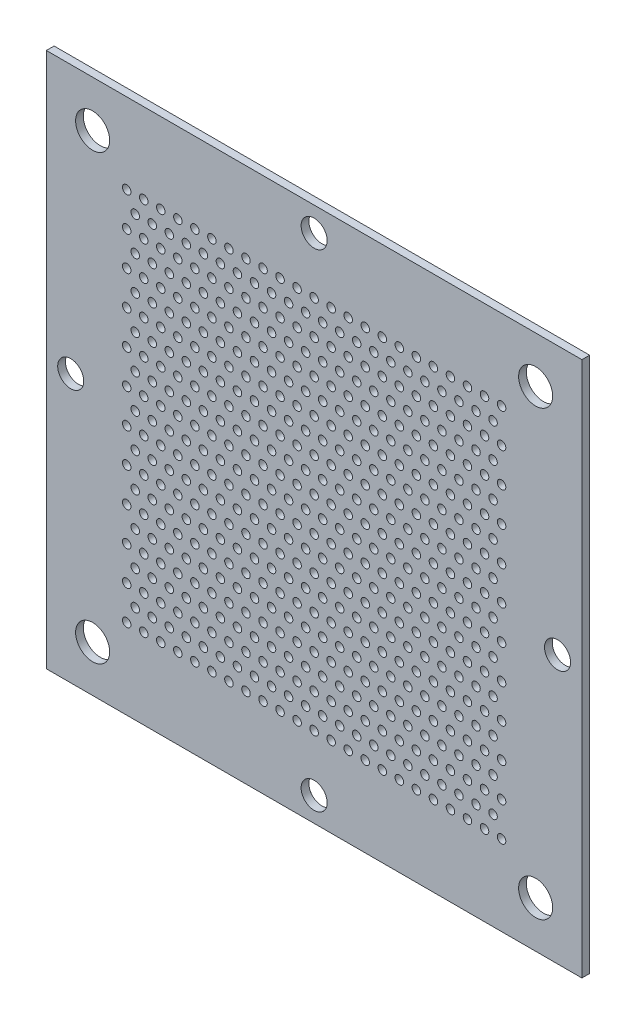
from build123d import *

# Parameters (mm, degrees)
MODEL_W             = 110
MODEL_H             = 110
MODEL_R             = 3.5
MODEL_R_2           = 0.875
MODEL_R_3           = 2.675
BOSS_EXTRUDE1_DEPTH = 1.5875


with BuildPart() as part:
    # Model → Boss-Extrude1 (new body)
    with BuildSketch(Plane.XY):
        with Locations((38.5, 38.5)):
            Rectangle(MODEL_W, MODEL_H)
        with Locations((84, 84)):
            Circle(MODEL_R, mode=Mode.SUBTRACT)
        with Locations((-7, 84)):
            Circle(MODEL_R, mode=Mode.SUBTRACT)
        with Locations((-7, -7)):
            Circle(MODEL_R, mode=Mode.SUBTRACT)
        with Locations((84, -7)):
            Circle(MODEL_R, mode=Mode.SUBTRACT)
        with Locations((77, 0)):
            Circle(MODEL_R_2, mode=Mode.SUBTRACT)
        with Locations((73.5, 0)):
            Circle(MODEL_R_2, mode=Mode.SUBTRACT)
        with Locations((70, 0)):
            Circle(MODEL_R_2, mode=Mode.SUBTRACT)
        with Locations((66.5, 0)):
            Circle(MODEL_R_2, mode=Mode.SUBTRACT)
        with Locations((63, 0)):
            Circle(MODEL_R_2, mode=Mode.SUBTRACT)
        with Locations((59.5, 0)):
            Circle(MODEL_R_2, mode=Mode.SUBTRACT)
        with Locations((56, 0)):
            Circle(MODEL_R_2, mode=Mode.SUBTRACT)
        with Locations((52.5, 0)):
            Circle(MODEL_R_2, mode=Mode.SUBTRACT)
        with Locations((49, 0)):
            Circle(MODEL_R_2, mode=Mode.SUBTRACT)
        with Locations((45.5, 0)):
            Circle(MODEL_R_2, mode=Mode.SUBTRACT)
        with Locations((42, 0)):
            Circle(MODEL_R_2, mode=Mode.SUBTRACT)
        with Locations((38.5, 0)):
            Circle(MODEL_R_2, mode=Mode.SUBTRACT)
        with Locations((35, 0)):
            Circle(MODEL_R_2, mode=Mode.SUBTRACT)
        with Locations((31.5, 0)):
            Circle(MODEL_R_2, mode=Mode.SUBTRACT)
        with Locations((28, 0)):
            Circle(MODEL_R_2, mode=Mode.SUBTRACT)
        with Locations((24.5, 0)):
            Circle(MODEL_R_2, mode=Mode.SUBTRACT)
        with Locations((21, 0)):
            Circle(MODEL_R_2, mode=Mode.SUBTRACT)
        with Locations((17.5, 0)):
            Circle(MODEL_R_2, mode=Mode.SUBTRACT)
        with Locations((14, 0)):
            Circle(MODEL_R_2, mode=Mode.SUBTRACT)
        with Locations((10.5, 0)):
            Circle(MODEL_R_2, mode=Mode.SUBTRACT)
        with Locations((7, 0)):
            Circle(MODEL_R_2, mode=Mode.SUBTRACT)
        with Locations((3.5, 0)):
            Circle(MODEL_R_2, mode=Mode.SUBTRACT)
        Circle(MODEL_R_2, mode=Mode.SUBTRACT)
        with Locations((75.25, 3.5)):
            Circle(MODEL_R_2, mode=Mode.SUBTRACT)
        with Locations((71.75, 3.5)):
            Circle(MODEL_R_2, mode=Mode.SUBTRACT)
        with Locations((68.25, 3.5)):
            Circle(MODEL_R_2, mode=Mode.SUBTRACT)
        with Locations((64.75, 3.5)):
            Circle(MODEL_R_2, mode=Mode.SUBTRACT)
        with Locations((61.25, 3.5)):
            Circle(MODEL_R_2, mode=Mode.SUBTRACT)
        with Locations((57.75, 3.5)):
            Circle(MODEL_R_2, mode=Mode.SUBTRACT)
        with Locations((54.25, 3.5)):
            Circle(MODEL_R_2, mode=Mode.SUBTRACT)
        with Locations((50.75, 3.5)):
            Circle(MODEL_R_2, mode=Mode.SUBTRACT)
        with Locations((47.25, 3.5)):
            Circle(MODEL_R_2, mode=Mode.SUBTRACT)
        with Locations((43.75, 3.5)):
            Circle(MODEL_R_2, mode=Mode.SUBTRACT)
        with Locations((40.25, 3.5)):
            Circle(MODEL_R_2, mode=Mode.SUBTRACT)
        with Locations((36.75, 3.5)):
            Circle(MODEL_R_2, mode=Mode.SUBTRACT)
        with Locations((33.25, 3.5)):
            Circle(MODEL_R_2, mode=Mode.SUBTRACT)
        with Locations((29.75, 3.5)):
            Circle(MODEL_R_2, mode=Mode.SUBTRACT)
        with Locations((26.25, 3.5)):
            Circle(MODEL_R_2, mode=Mode.SUBTRACT)
        with Locations((22.75, 3.5)):
            Circle(MODEL_R_2, mode=Mode.SUBTRACT)
        with Locations((19.25, 3.5)):
            Circle(MODEL_R_2, mode=Mode.SUBTRACT)
        with Locations((15.75, 3.5)):
            Circle(MODEL_R_2, mode=Mode.SUBTRACT)
        with Locations((12.25, 3.5)):
            Circle(MODEL_R_2, mode=Mode.SUBTRACT)
        with Locations((8.75, 3.5)):
            Circle(MODEL_R_2, mode=Mode.SUBTRACT)
        with Locations((5.25, 3.5)):
            Circle(MODEL_R_2, mode=Mode.SUBTRACT)
        with Locations((1.75, 3.5)):
            Circle(MODEL_R_2, mode=Mode.SUBTRACT)
        with Locations((77, 7)):
            Circle(MODEL_R_2, mode=Mode.SUBTRACT)
        with Locations((73.5, 7)):
            Circle(MODEL_R_2, mode=Mode.SUBTRACT)
        with Locations((70, 7)):
            Circle(MODEL_R_2, mode=Mode.SUBTRACT)
        with Locations((66.5, 7)):
            Circle(MODEL_R_2, mode=Mode.SUBTRACT)
        with Locations((63, 7)):
            Circle(MODEL_R_2, mode=Mode.SUBTRACT)
        with Locations((59.5, 7)):
            Circle(MODEL_R_2, mode=Mode.SUBTRACT)
        with Locations((56, 7)):
            Circle(MODEL_R_2, mode=Mode.SUBTRACT)
        with Locations((52.5, 7)):
            Circle(MODEL_R_2, mode=Mode.SUBTRACT)
        with Locations((49, 7)):
            Circle(MODEL_R_2, mode=Mode.SUBTRACT)
        with Locations((45.5, 7)):
            Circle(MODEL_R_2, mode=Mode.SUBTRACT)
        with Locations((42, 7)):
            Circle(MODEL_R_2, mode=Mode.SUBTRACT)
        with Locations((38.5, 7)):
            Circle(MODEL_R_2, mode=Mode.SUBTRACT)
        with Locations((35, 7)):
            Circle(MODEL_R_2, mode=Mode.SUBTRACT)
        with Locations((31.5, 7)):
            Circle(MODEL_R_2, mode=Mode.SUBTRACT)
        with Locations((28, 7)):
            Circle(MODEL_R_2, mode=Mode.SUBTRACT)
        with Locations((24.5, 7)):
            Circle(MODEL_R_2, mode=Mode.SUBTRACT)
        with Locations((21, 7)):
            Circle(MODEL_R_2, mode=Mode.SUBTRACT)
        with Locations((17.5, 7)):
            Circle(MODEL_R_2, mode=Mode.SUBTRACT)
        with Locations((14, 7)):
            Circle(MODEL_R_2, mode=Mode.SUBTRACT)
        with Locations((10.5, 7)):
            Circle(MODEL_R_2, mode=Mode.SUBTRACT)
        with Locations((7, 7)):
            Circle(MODEL_R_2, mode=Mode.SUBTRACT)
        with Locations((3.5, 7)):
            Circle(MODEL_R_2, mode=Mode.SUBTRACT)
        with Locations((0, 7)):
            Circle(MODEL_R_2, mode=Mode.SUBTRACT)
        with Locations((75.25, 10.5)):
            Circle(MODEL_R_2, mode=Mode.SUBTRACT)
        with Locations((71.75, 10.5)):
            Circle(MODEL_R_2, mode=Mode.SUBTRACT)
        with Locations((68.25, 10.5)):
            Circle(MODEL_R_2, mode=Mode.SUBTRACT)
        with Locations((64.75, 10.5)):
            Circle(MODEL_R_2, mode=Mode.SUBTRACT)
        with Locations((61.25, 10.5)):
            Circle(MODEL_R_2, mode=Mode.SUBTRACT)
        with Locations((57.75, 10.5)):
            Circle(MODEL_R_2, mode=Mode.SUBTRACT)
        with Locations((54.25, 10.5)):
            Circle(MODEL_R_2, mode=Mode.SUBTRACT)
        with Locations((50.75, 10.5)):
            Circle(MODEL_R_2, mode=Mode.SUBTRACT)
        with Locations((47.25, 10.5)):
            Circle(MODEL_R_2, mode=Mode.SUBTRACT)
        with Locations((43.75, 10.5)):
            Circle(MODEL_R_2, mode=Mode.SUBTRACT)
        with Locations((40.25, 10.5)):
            Circle(MODEL_R_2, mode=Mode.SUBTRACT)
        with Locations((36.75, 10.5)):
            Circle(MODEL_R_2, mode=Mode.SUBTRACT)
        with Locations((33.25, 10.5)):
            Circle(MODEL_R_2, mode=Mode.SUBTRACT)
        with Locations((29.75, 10.5)):
            Circle(MODEL_R_2, mode=Mode.SUBTRACT)
        with Locations((26.25, 10.5)):
            Circle(MODEL_R_2, mode=Mode.SUBTRACT)
        with Locations((22.75, 10.5)):
            Circle(MODEL_R_2, mode=Mode.SUBTRACT)
        with Locations((19.25, 10.5)):
            Circle(MODEL_R_2, mode=Mode.SUBTRACT)
        with Locations((15.75, 10.5)):
            Circle(MODEL_R_2, mode=Mode.SUBTRACT)
        with Locations((12.25, 10.5)):
            Circle(MODEL_R_2, mode=Mode.SUBTRACT)
        with Locations((8.75, 10.5)):
            Circle(MODEL_R_2, mode=Mode.SUBTRACT)
        with Locations((5.25, 10.5)):
            Circle(MODEL_R_2, mode=Mode.SUBTRACT)
        with Locations((1.75, 10.5)):
            Circle(MODEL_R_2, mode=Mode.SUBTRACT)
        with Locations((77, 14)):
            Circle(MODEL_R_2, mode=Mode.SUBTRACT)
        with Locations((73.5, 14)):
            Circle(MODEL_R_2, mode=Mode.SUBTRACT)
        with Locations((70, 14)):
            Circle(MODEL_R_2, mode=Mode.SUBTRACT)
        with Locations((66.5, 14)):
            Circle(MODEL_R_2, mode=Mode.SUBTRACT)
        with Locations((63, 14)):
            Circle(MODEL_R_2, mode=Mode.SUBTRACT)
        with Locations((59.5, 14)):
            Circle(MODEL_R_2, mode=Mode.SUBTRACT)
        with Locations((56, 14)):
            Circle(MODEL_R_2, mode=Mode.SUBTRACT)
        with Locations((52.5, 14)):
            Circle(MODEL_R_2, mode=Mode.SUBTRACT)
        with Locations((49, 14)):
            Circle(MODEL_R_2, mode=Mode.SUBTRACT)
        with Locations((45.5, 14)):
            Circle(MODEL_R_2, mode=Mode.SUBTRACT)
        with Locations((42, 14)):
            Circle(MODEL_R_2, mode=Mode.SUBTRACT)
        with Locations((38.5, 14)):
            Circle(MODEL_R_2, mode=Mode.SUBTRACT)
        with Locations((35, 14)):
            Circle(MODEL_R_2, mode=Mode.SUBTRACT)
        with Locations((31.5, 14)):
            Circle(MODEL_R_2, mode=Mode.SUBTRACT)
        with Locations((28, 14)):
            Circle(MODEL_R_2, mode=Mode.SUBTRACT)
        with Locations((24.5, 14)):
            Circle(MODEL_R_2, mode=Mode.SUBTRACT)
        with Locations((21, 14)):
            Circle(MODEL_R_2, mode=Mode.SUBTRACT)
        with Locations((17.5, 14)):
            Circle(MODEL_R_2, mode=Mode.SUBTRACT)
        with Locations((14, 14)):
            Circle(MODEL_R_2, mode=Mode.SUBTRACT)
        with Locations((10.5, 14)):
            Circle(MODEL_R_2, mode=Mode.SUBTRACT)
        with Locations((7, 14)):
            Circle(MODEL_R_2, mode=Mode.SUBTRACT)
        with Locations((3.5, 14)):
            Circle(MODEL_R_2, mode=Mode.SUBTRACT)
        with Locations((0, 14)):
            Circle(MODEL_R_2, mode=Mode.SUBTRACT)
        with Locations((75.25, 17.5)):
            Circle(MODEL_R_2, mode=Mode.SUBTRACT)
        with Locations((71.75, 17.5)):
            Circle(MODEL_R_2, mode=Mode.SUBTRACT)
        with Locations((68.25, 17.5)):
            Circle(MODEL_R_2, mode=Mode.SUBTRACT)
        with Locations((64.75, 17.5)):
            Circle(MODEL_R_2, mode=Mode.SUBTRACT)
        with Locations((61.25, 17.5)):
            Circle(MODEL_R_2, mode=Mode.SUBTRACT)
        with Locations((57.75, 17.5)):
            Circle(MODEL_R_2, mode=Mode.SUBTRACT)
        with Locations((54.25, 17.5)):
            Circle(MODEL_R_2, mode=Mode.SUBTRACT)
        with Locations((50.75, 17.5)):
            Circle(MODEL_R_2, mode=Mode.SUBTRACT)
        with Locations((47.25, 17.5)):
            Circle(MODEL_R_2, mode=Mode.SUBTRACT)
        with Locations((43.75, 17.5)):
            Circle(MODEL_R_2, mode=Mode.SUBTRACT)
        with Locations((40.25, 17.5)):
            Circle(MODEL_R_2, mode=Mode.SUBTRACT)
        with Locations((36.75, 17.5)):
            Circle(MODEL_R_2, mode=Mode.SUBTRACT)
        with Locations((33.25, 17.5)):
            Circle(MODEL_R_2, mode=Mode.SUBTRACT)
        with Locations((29.75, 17.5)):
            Circle(MODEL_R_2, mode=Mode.SUBTRACT)
        with Locations((26.25, 17.5)):
            Circle(MODEL_R_2, mode=Mode.SUBTRACT)
        with Locations((22.75, 17.5)):
            Circle(MODEL_R_2, mode=Mode.SUBTRACT)
        with Locations((19.25, 17.5)):
            Circle(MODEL_R_2, mode=Mode.SUBTRACT)
        with Locations((15.75, 17.5)):
            Circle(MODEL_R_2, mode=Mode.SUBTRACT)
        with Locations((12.25, 17.5)):
            Circle(MODEL_R_2, mode=Mode.SUBTRACT)
        with Locations((8.75, 17.5)):
            Circle(MODEL_R_2, mode=Mode.SUBTRACT)
        with Locations((5.25, 17.5)):
            Circle(MODEL_R_2, mode=Mode.SUBTRACT)
        with Locations((1.75, 17.5)):
            Circle(MODEL_R_2, mode=Mode.SUBTRACT)
        with Locations((77, 21)):
            Circle(MODEL_R_2, mode=Mode.SUBTRACT)
        with Locations((73.5, 21)):
            Circle(MODEL_R_2, mode=Mode.SUBTRACT)
        with Locations((70, 21)):
            Circle(MODEL_R_2, mode=Mode.SUBTRACT)
        with Locations((66.5, 21)):
            Circle(MODEL_R_2, mode=Mode.SUBTRACT)
        with Locations((63, 21)):
            Circle(MODEL_R_2, mode=Mode.SUBTRACT)
        with Locations((59.5, 21)):
            Circle(MODEL_R_2, mode=Mode.SUBTRACT)
        with Locations((56, 21)):
            Circle(MODEL_R_2, mode=Mode.SUBTRACT)
        with Locations((52.5, 21)):
            Circle(MODEL_R_2, mode=Mode.SUBTRACT)
        with Locations((49, 21)):
            Circle(MODEL_R_2, mode=Mode.SUBTRACT)
        with Locations((45.5, 21)):
            Circle(MODEL_R_2, mode=Mode.SUBTRACT)
        with Locations((42, 21)):
            Circle(MODEL_R_2, mode=Mode.SUBTRACT)
        with Locations((38.5, 21)):
            Circle(MODEL_R_2, mode=Mode.SUBTRACT)
        with Locations((35, 21)):
            Circle(MODEL_R_2, mode=Mode.SUBTRACT)
        with Locations((31.5, 21)):
            Circle(MODEL_R_2, mode=Mode.SUBTRACT)
        with Locations((28, 21)):
            Circle(MODEL_R_2, mode=Mode.SUBTRACT)
        with Locations((24.5, 21)):
            Circle(MODEL_R_2, mode=Mode.SUBTRACT)
        with Locations((21, 21)):
            Circle(MODEL_R_2, mode=Mode.SUBTRACT)
        with Locations((17.5, 21)):
            Circle(MODEL_R_2, mode=Mode.SUBTRACT)
        with Locations((14, 21)):
            Circle(MODEL_R_2, mode=Mode.SUBTRACT)
        with Locations((10.5, 21)):
            Circle(MODEL_R_2, mode=Mode.SUBTRACT)
        with Locations((7, 21)):
            Circle(MODEL_R_2, mode=Mode.SUBTRACT)
        with Locations((3.5, 21)):
            Circle(MODEL_R_2, mode=Mode.SUBTRACT)
        with Locations((0, 21)):
            Circle(MODEL_R_2, mode=Mode.SUBTRACT)
        with Locations((75.25, 24.5)):
            Circle(MODEL_R_2, mode=Mode.SUBTRACT)
        with Locations((71.75, 24.5)):
            Circle(MODEL_R_2, mode=Mode.SUBTRACT)
        with Locations((68.25, 24.5)):
            Circle(MODEL_R_2, mode=Mode.SUBTRACT)
        with Locations((64.75, 24.5)):
            Circle(MODEL_R_2, mode=Mode.SUBTRACT)
        with Locations((61.25, 24.5)):
            Circle(MODEL_R_2, mode=Mode.SUBTRACT)
        with Locations((57.75, 24.5)):
            Circle(MODEL_R_2, mode=Mode.SUBTRACT)
        with Locations((54.25, 24.5)):
            Circle(MODEL_R_2, mode=Mode.SUBTRACT)
        with Locations((50.75, 24.5)):
            Circle(MODEL_R_2, mode=Mode.SUBTRACT)
        with Locations((47.25, 24.5)):
            Circle(MODEL_R_2, mode=Mode.SUBTRACT)
        with Locations((43.75, 24.5)):
            Circle(MODEL_R_2, mode=Mode.SUBTRACT)
        with Locations((40.25, 24.5)):
            Circle(MODEL_R_2, mode=Mode.SUBTRACT)
        with Locations((36.75, 24.5)):
            Circle(MODEL_R_2, mode=Mode.SUBTRACT)
        with Locations((33.25, 24.5)):
            Circle(MODEL_R_2, mode=Mode.SUBTRACT)
        with Locations((29.75, 24.5)):
            Circle(MODEL_R_2, mode=Mode.SUBTRACT)
        with Locations((26.25, 24.5)):
            Circle(MODEL_R_2, mode=Mode.SUBTRACT)
        with Locations((22.75, 24.5)):
            Circle(MODEL_R_2, mode=Mode.SUBTRACT)
        with Locations((19.25, 24.5)):
            Circle(MODEL_R_2, mode=Mode.SUBTRACT)
        with Locations((15.75, 24.5)):
            Circle(MODEL_R_2, mode=Mode.SUBTRACT)
        with Locations((12.25, 24.5)):
            Circle(MODEL_R_2, mode=Mode.SUBTRACT)
        with Locations((8.75, 24.5)):
            Circle(MODEL_R_2, mode=Mode.SUBTRACT)
        with Locations((5.25, 24.5)):
            Circle(MODEL_R_2, mode=Mode.SUBTRACT)
        with Locations((1.75, 24.5)):
            Circle(MODEL_R_2, mode=Mode.SUBTRACT)
        with Locations((77, 28)):
            Circle(MODEL_R_2, mode=Mode.SUBTRACT)
        with Locations((73.5, 28)):
            Circle(MODEL_R_2, mode=Mode.SUBTRACT)
        with Locations((70, 28)):
            Circle(MODEL_R_2, mode=Mode.SUBTRACT)
        with Locations((66.5, 28)):
            Circle(MODEL_R_2, mode=Mode.SUBTRACT)
        with Locations((63, 28)):
            Circle(MODEL_R_2, mode=Mode.SUBTRACT)
        with Locations((59.5, 28)):
            Circle(MODEL_R_2, mode=Mode.SUBTRACT)
        with Locations((56, 28)):
            Circle(MODEL_R_2, mode=Mode.SUBTRACT)
        with Locations((52.5, 28)):
            Circle(MODEL_R_2, mode=Mode.SUBTRACT)
        with Locations((49, 28)):
            Circle(MODEL_R_2, mode=Mode.SUBTRACT)
        with Locations((45.5, 28)):
            Circle(MODEL_R_2, mode=Mode.SUBTRACT)
        with Locations((42, 28)):
            Circle(MODEL_R_2, mode=Mode.SUBTRACT)
        with Locations((38.5, 28)):
            Circle(MODEL_R_2, mode=Mode.SUBTRACT)
        with Locations((35, 28)):
            Circle(MODEL_R_2, mode=Mode.SUBTRACT)
        with Locations((31.5, 28)):
            Circle(MODEL_R_2, mode=Mode.SUBTRACT)
        with Locations((28, 28)):
            Circle(MODEL_R_2, mode=Mode.SUBTRACT)
        with Locations((24.5, 28)):
            Circle(MODEL_R_2, mode=Mode.SUBTRACT)
        with Locations((21, 28)):
            Circle(MODEL_R_2, mode=Mode.SUBTRACT)
        with Locations((17.5, 28)):
            Circle(MODEL_R_2, mode=Mode.SUBTRACT)
        with Locations((14, 28)):
            Circle(MODEL_R_2, mode=Mode.SUBTRACT)
        with Locations((10.5, 28)):
            Circle(MODEL_R_2, mode=Mode.SUBTRACT)
        with Locations((7, 28)):
            Circle(MODEL_R_2, mode=Mode.SUBTRACT)
        with Locations((3.5, 28)):
            Circle(MODEL_R_2, mode=Mode.SUBTRACT)
        with Locations((0, 28)):
            Circle(MODEL_R_2, mode=Mode.SUBTRACT)
        with Locations((75.25, 31.5)):
            Circle(MODEL_R_2, mode=Mode.SUBTRACT)
        with Locations((71.75, 31.5)):
            Circle(MODEL_R_2, mode=Mode.SUBTRACT)
        with Locations((68.25, 31.5)):
            Circle(MODEL_R_2, mode=Mode.SUBTRACT)
        with Locations((64.75, 31.5)):
            Circle(MODEL_R_2, mode=Mode.SUBTRACT)
        with Locations((61.25, 31.5)):
            Circle(MODEL_R_2, mode=Mode.SUBTRACT)
        with Locations((57.75, 31.5)):
            Circle(MODEL_R_2, mode=Mode.SUBTRACT)
        with Locations((54.25, 31.5)):
            Circle(MODEL_R_2, mode=Mode.SUBTRACT)
        with Locations((50.75, 31.5)):
            Circle(MODEL_R_2, mode=Mode.SUBTRACT)
        with Locations((47.25, 31.5)):
            Circle(MODEL_R_2, mode=Mode.SUBTRACT)
        with Locations((43.75, 31.5)):
            Circle(MODEL_R_2, mode=Mode.SUBTRACT)
        with Locations((40.25, 31.5)):
            Circle(MODEL_R_2, mode=Mode.SUBTRACT)
        with Locations((36.75, 31.5)):
            Circle(MODEL_R_2, mode=Mode.SUBTRACT)
        with Locations((33.25, 31.5)):
            Circle(MODEL_R_2, mode=Mode.SUBTRACT)
        with Locations((29.75, 31.5)):
            Circle(MODEL_R_2, mode=Mode.SUBTRACT)
        with Locations((26.25, 31.5)):
            Circle(MODEL_R_2, mode=Mode.SUBTRACT)
        with Locations((22.75, 31.5)):
            Circle(MODEL_R_2, mode=Mode.SUBTRACT)
        with Locations((19.25, 31.5)):
            Circle(MODEL_R_2, mode=Mode.SUBTRACT)
        with Locations((15.75, 31.5)):
            Circle(MODEL_R_2, mode=Mode.SUBTRACT)
        with Locations((12.25, 31.5)):
            Circle(MODEL_R_2, mode=Mode.SUBTRACT)
        with Locations((8.75, 31.5)):
            Circle(MODEL_R_2, mode=Mode.SUBTRACT)
        with Locations((5.25, 31.5)):
            Circle(MODEL_R_2, mode=Mode.SUBTRACT)
        with Locations((1.75, 31.5)):
            Circle(MODEL_R_2, mode=Mode.SUBTRACT)
        with Locations((77, 35)):
            Circle(MODEL_R_2, mode=Mode.SUBTRACT)
        with Locations((73.5, 35)):
            Circle(MODEL_R_2, mode=Mode.SUBTRACT)
        with Locations((70, 35)):
            Circle(MODEL_R_2, mode=Mode.SUBTRACT)
        with Locations((66.5, 35)):
            Circle(MODEL_R_2, mode=Mode.SUBTRACT)
        with Locations((63, 35)):
            Circle(MODEL_R_2, mode=Mode.SUBTRACT)
        with Locations((59.5, 35)):
            Circle(MODEL_R_2, mode=Mode.SUBTRACT)
        with Locations((56, 35)):
            Circle(MODEL_R_2, mode=Mode.SUBTRACT)
        with Locations((52.5, 35)):
            Circle(MODEL_R_2, mode=Mode.SUBTRACT)
        with Locations((49, 35)):
            Circle(MODEL_R_2, mode=Mode.SUBTRACT)
        with Locations((45.5, 35)):
            Circle(MODEL_R_2, mode=Mode.SUBTRACT)
        with Locations((42, 35)):
            Circle(MODEL_R_2, mode=Mode.SUBTRACT)
        with Locations((38.5, 35)):
            Circle(MODEL_R_2, mode=Mode.SUBTRACT)
        with Locations((35, 35)):
            Circle(MODEL_R_2, mode=Mode.SUBTRACT)
        with Locations((31.5, 35)):
            Circle(MODEL_R_2, mode=Mode.SUBTRACT)
        with Locations((28, 35)):
            Circle(MODEL_R_2, mode=Mode.SUBTRACT)
        with Locations((24.5, 35)):
            Circle(MODEL_R_2, mode=Mode.SUBTRACT)
        with Locations((21, 35)):
            Circle(MODEL_R_2, mode=Mode.SUBTRACT)
        with Locations((17.5, 35)):
            Circle(MODEL_R_2, mode=Mode.SUBTRACT)
        with Locations((14, 35)):
            Circle(MODEL_R_2, mode=Mode.SUBTRACT)
        with Locations((10.5, 35)):
            Circle(MODEL_R_2, mode=Mode.SUBTRACT)
        with Locations((7, 35)):
            Circle(MODEL_R_2, mode=Mode.SUBTRACT)
        with Locations((3.5, 35)):
            Circle(MODEL_R_2, mode=Mode.SUBTRACT)
        with Locations((0, 35)):
            Circle(MODEL_R_2, mode=Mode.SUBTRACT)
        with Locations((75.25, 38.5)):
            Circle(MODEL_R_2, mode=Mode.SUBTRACT)
        with Locations((71.75, 38.5)):
            Circle(MODEL_R_2, mode=Mode.SUBTRACT)
        with Locations((68.25, 38.5)):
            Circle(MODEL_R_2, mode=Mode.SUBTRACT)
        with Locations((64.75, 38.5)):
            Circle(MODEL_R_2, mode=Mode.SUBTRACT)
        with Locations((61.25, 38.5)):
            Circle(MODEL_R_2, mode=Mode.SUBTRACT)
        with Locations((57.75, 38.5)):
            Circle(MODEL_R_2, mode=Mode.SUBTRACT)
        with Locations((54.25, 38.5)):
            Circle(MODEL_R_2, mode=Mode.SUBTRACT)
        with Locations((50.75, 38.5)):
            Circle(MODEL_R_2, mode=Mode.SUBTRACT)
        with Locations((47.25, 38.5)):
            Circle(MODEL_R_2, mode=Mode.SUBTRACT)
        with Locations((43.75, 38.5)):
            Circle(MODEL_R_2, mode=Mode.SUBTRACT)
        with Locations((40.25, 38.5)):
            Circle(MODEL_R_2, mode=Mode.SUBTRACT)
        with Locations((36.75, 38.5)):
            Circle(MODEL_R_2, mode=Mode.SUBTRACT)
        with Locations((33.25, 38.5)):
            Circle(MODEL_R_2, mode=Mode.SUBTRACT)
        with Locations((29.75, 38.5)):
            Circle(MODEL_R_2, mode=Mode.SUBTRACT)
        with Locations((26.25, 38.5)):
            Circle(MODEL_R_2, mode=Mode.SUBTRACT)
        with Locations((22.75, 38.5)):
            Circle(MODEL_R_2, mode=Mode.SUBTRACT)
        with Locations((19.25, 38.5)):
            Circle(MODEL_R_2, mode=Mode.SUBTRACT)
        with Locations((15.75, 38.5)):
            Circle(MODEL_R_2, mode=Mode.SUBTRACT)
        with Locations((12.25, 38.5)):
            Circle(MODEL_R_2, mode=Mode.SUBTRACT)
        with Locations((8.75, 38.5)):
            Circle(MODEL_R_2, mode=Mode.SUBTRACT)
        with Locations((5.25, 38.5)):
            Circle(MODEL_R_2, mode=Mode.SUBTRACT)
        with Locations((1.75, 38.5)):
            Circle(MODEL_R_2, mode=Mode.SUBTRACT)
        with Locations((77, 42)):
            Circle(MODEL_R_2, mode=Mode.SUBTRACT)
        with Locations((73.5, 42)):
            Circle(MODEL_R_2, mode=Mode.SUBTRACT)
        with Locations((70, 42)):
            Circle(MODEL_R_2, mode=Mode.SUBTRACT)
        with Locations((66.5, 42)):
            Circle(MODEL_R_2, mode=Mode.SUBTRACT)
        with Locations((63, 42)):
            Circle(MODEL_R_2, mode=Mode.SUBTRACT)
        with Locations((59.5, 42)):
            Circle(MODEL_R_2, mode=Mode.SUBTRACT)
        with Locations((56, 42)):
            Circle(MODEL_R_2, mode=Mode.SUBTRACT)
        with Locations((52.5, 42)):
            Circle(MODEL_R_2, mode=Mode.SUBTRACT)
        with Locations((49, 42)):
            Circle(MODEL_R_2, mode=Mode.SUBTRACT)
        with Locations((45.5, 42)):
            Circle(MODEL_R_2, mode=Mode.SUBTRACT)
        with Locations((42, 42)):
            Circle(MODEL_R_2, mode=Mode.SUBTRACT)
        with Locations((38.5, 42)):
            Circle(MODEL_R_2, mode=Mode.SUBTRACT)
        with Locations((35, 42)):
            Circle(MODEL_R_2, mode=Mode.SUBTRACT)
        with Locations((31.5, 42)):
            Circle(MODEL_R_2, mode=Mode.SUBTRACT)
        with Locations((28, 42)):
            Circle(MODEL_R_2, mode=Mode.SUBTRACT)
        with Locations((24.5, 42)):
            Circle(MODEL_R_2, mode=Mode.SUBTRACT)
        with Locations((21, 42)):
            Circle(MODEL_R_2, mode=Mode.SUBTRACT)
        with Locations((17.5, 42)):
            Circle(MODEL_R_2, mode=Mode.SUBTRACT)
        with Locations((14, 42)):
            Circle(MODEL_R_2, mode=Mode.SUBTRACT)
        with Locations((10.5, 42)):
            Circle(MODEL_R_2, mode=Mode.SUBTRACT)
        with Locations((7, 42)):
            Circle(MODEL_R_2, mode=Mode.SUBTRACT)
        with Locations((3.5, 42)):
            Circle(MODEL_R_2, mode=Mode.SUBTRACT)
        with Locations((0, 42)):
            Circle(MODEL_R_2, mode=Mode.SUBTRACT)
        with Locations((75.25, 45.5)):
            Circle(MODEL_R_2, mode=Mode.SUBTRACT)
        with Locations((71.75, 45.5)):
            Circle(MODEL_R_2, mode=Mode.SUBTRACT)
        with Locations((68.25, 45.5)):
            Circle(MODEL_R_2, mode=Mode.SUBTRACT)
        with Locations((64.75, 45.5)):
            Circle(MODEL_R_2, mode=Mode.SUBTRACT)
        with Locations((61.25, 45.5)):
            Circle(MODEL_R_2, mode=Mode.SUBTRACT)
        with Locations((57.75, 45.5)):
            Circle(MODEL_R_2, mode=Mode.SUBTRACT)
        with Locations((54.25, 45.5)):
            Circle(MODEL_R_2, mode=Mode.SUBTRACT)
        with Locations((50.75, 45.5)):
            Circle(MODEL_R_2, mode=Mode.SUBTRACT)
        with Locations((47.25, 45.5)):
            Circle(MODEL_R_2, mode=Mode.SUBTRACT)
        with Locations((43.75, 45.5)):
            Circle(MODEL_R_2, mode=Mode.SUBTRACT)
        with Locations((40.25, 45.5)):
            Circle(MODEL_R_2, mode=Mode.SUBTRACT)
        with Locations((36.75, 45.5)):
            Circle(MODEL_R_2, mode=Mode.SUBTRACT)
        with Locations((33.25, 45.5)):
            Circle(MODEL_R_2, mode=Mode.SUBTRACT)
        with Locations((29.75, 45.5)):
            Circle(MODEL_R_2, mode=Mode.SUBTRACT)
        with Locations((26.25, 45.5)):
            Circle(MODEL_R_2, mode=Mode.SUBTRACT)
        with Locations((22.75, 45.5)):
            Circle(MODEL_R_2, mode=Mode.SUBTRACT)
        with Locations((19.25, 45.5)):
            Circle(MODEL_R_2, mode=Mode.SUBTRACT)
        with Locations((15.75, 45.5)):
            Circle(MODEL_R_2, mode=Mode.SUBTRACT)
        with Locations((12.25, 45.5)):
            Circle(MODEL_R_2, mode=Mode.SUBTRACT)
        with Locations((8.75, 45.5)):
            Circle(MODEL_R_2, mode=Mode.SUBTRACT)
        with Locations((5.25, 45.5)):
            Circle(MODEL_R_2, mode=Mode.SUBTRACT)
        with Locations((1.75, 45.5)):
            Circle(MODEL_R_2, mode=Mode.SUBTRACT)
        with Locations((77, 49)):
            Circle(MODEL_R_2, mode=Mode.SUBTRACT)
        with Locations((73.5, 49)):
            Circle(MODEL_R_2, mode=Mode.SUBTRACT)
        with Locations((70, 49)):
            Circle(MODEL_R_2, mode=Mode.SUBTRACT)
        with Locations((66.5, 49)):
            Circle(MODEL_R_2, mode=Mode.SUBTRACT)
        with Locations((63, 49)):
            Circle(MODEL_R_2, mode=Mode.SUBTRACT)
        with Locations((59.5, 49)):
            Circle(MODEL_R_2, mode=Mode.SUBTRACT)
        with Locations((56, 49)):
            Circle(MODEL_R_2, mode=Mode.SUBTRACT)
        with Locations((52.5, 49)):
            Circle(MODEL_R_2, mode=Mode.SUBTRACT)
        with Locations((49, 49)):
            Circle(MODEL_R_2, mode=Mode.SUBTRACT)
        with Locations((45.5, 49)):
            Circle(MODEL_R_2, mode=Mode.SUBTRACT)
        with Locations((42, 49)):
            Circle(MODEL_R_2, mode=Mode.SUBTRACT)
        with Locations((38.5, 49)):
            Circle(MODEL_R_2, mode=Mode.SUBTRACT)
        with Locations((35, 49)):
            Circle(MODEL_R_2, mode=Mode.SUBTRACT)
        with Locations((31.5, 49)):
            Circle(MODEL_R_2, mode=Mode.SUBTRACT)
        with Locations((28, 49)):
            Circle(MODEL_R_2, mode=Mode.SUBTRACT)
        with Locations((24.5, 49)):
            Circle(MODEL_R_2, mode=Mode.SUBTRACT)
        with Locations((21, 49)):
            Circle(MODEL_R_2, mode=Mode.SUBTRACT)
        with Locations((17.5, 49)):
            Circle(MODEL_R_2, mode=Mode.SUBTRACT)
        with Locations((14, 49)):
            Circle(MODEL_R_2, mode=Mode.SUBTRACT)
        with Locations((10.5, 49)):
            Circle(MODEL_R_2, mode=Mode.SUBTRACT)
        with Locations((7, 49)):
            Circle(MODEL_R_2, mode=Mode.SUBTRACT)
        with Locations((3.5, 49)):
            Circle(MODEL_R_2, mode=Mode.SUBTRACT)
        with Locations((0, 49)):
            Circle(MODEL_R_2, mode=Mode.SUBTRACT)
        with Locations((75.25, 52.5)):
            Circle(MODEL_R_2, mode=Mode.SUBTRACT)
        with Locations((71.75, 52.5)):
            Circle(MODEL_R_2, mode=Mode.SUBTRACT)
        with Locations((68.25, 52.5)):
            Circle(MODEL_R_2, mode=Mode.SUBTRACT)
        with Locations((64.75, 52.5)):
            Circle(MODEL_R_2, mode=Mode.SUBTRACT)
        with Locations((61.25, 52.5)):
            Circle(MODEL_R_2, mode=Mode.SUBTRACT)
        with Locations((57.75, 52.5)):
            Circle(MODEL_R_2, mode=Mode.SUBTRACT)
        with Locations((54.25, 52.5)):
            Circle(MODEL_R_2, mode=Mode.SUBTRACT)
        with Locations((50.75, 52.5)):
            Circle(MODEL_R_2, mode=Mode.SUBTRACT)
        with Locations((47.25, 52.5)):
            Circle(MODEL_R_2, mode=Mode.SUBTRACT)
        with Locations((43.75, 52.5)):
            Circle(MODEL_R_2, mode=Mode.SUBTRACT)
        with Locations((40.25, 52.5)):
            Circle(MODEL_R_2, mode=Mode.SUBTRACT)
        with Locations((36.75, 52.5)):
            Circle(MODEL_R_2, mode=Mode.SUBTRACT)
        with Locations((33.25, 52.5)):
            Circle(MODEL_R_2, mode=Mode.SUBTRACT)
        with Locations((29.75, 52.5)):
            Circle(MODEL_R_2, mode=Mode.SUBTRACT)
        with Locations((26.25, 52.5)):
            Circle(MODEL_R_2, mode=Mode.SUBTRACT)
        with Locations((22.75, 52.5)):
            Circle(MODEL_R_2, mode=Mode.SUBTRACT)
        with Locations((19.25, 52.5)):
            Circle(MODEL_R_2, mode=Mode.SUBTRACT)
        with Locations((15.75, 52.5)):
            Circle(MODEL_R_2, mode=Mode.SUBTRACT)
        with Locations((12.25, 52.5)):
            Circle(MODEL_R_2, mode=Mode.SUBTRACT)
        with Locations((8.75, 52.5)):
            Circle(MODEL_R_2, mode=Mode.SUBTRACT)
        with Locations((5.25, 52.5)):
            Circle(MODEL_R_2, mode=Mode.SUBTRACT)
        with Locations((1.75, 52.5)):
            Circle(MODEL_R_2, mode=Mode.SUBTRACT)
        with Locations((77, 56)):
            Circle(MODEL_R_2, mode=Mode.SUBTRACT)
        with Locations((73.5, 56)):
            Circle(MODEL_R_2, mode=Mode.SUBTRACT)
        with Locations((70, 56)):
            Circle(MODEL_R_2, mode=Mode.SUBTRACT)
        with Locations((66.5, 56)):
            Circle(MODEL_R_2, mode=Mode.SUBTRACT)
        with Locations((63, 56)):
            Circle(MODEL_R_2, mode=Mode.SUBTRACT)
        with Locations((59.5, 56)):
            Circle(MODEL_R_2, mode=Mode.SUBTRACT)
        with Locations((56, 56)):
            Circle(MODEL_R_2, mode=Mode.SUBTRACT)
        with Locations((52.5, 56)):
            Circle(MODEL_R_2, mode=Mode.SUBTRACT)
        with Locations((49, 56)):
            Circle(MODEL_R_2, mode=Mode.SUBTRACT)
        with Locations((45.5, 56)):
            Circle(MODEL_R_2, mode=Mode.SUBTRACT)
        with Locations((42, 56)):
            Circle(MODEL_R_2, mode=Mode.SUBTRACT)
        with Locations((38.5, 56)):
            Circle(MODEL_R_2, mode=Mode.SUBTRACT)
        with Locations((35, 56)):
            Circle(MODEL_R_2, mode=Mode.SUBTRACT)
        with Locations((31.5, 56)):
            Circle(MODEL_R_2, mode=Mode.SUBTRACT)
        with Locations((28, 56)):
            Circle(MODEL_R_2, mode=Mode.SUBTRACT)
        with Locations((24.5, 56)):
            Circle(MODEL_R_2, mode=Mode.SUBTRACT)
        with Locations((21, 56)):
            Circle(MODEL_R_2, mode=Mode.SUBTRACT)
        with Locations((17.5, 56)):
            Circle(MODEL_R_2, mode=Mode.SUBTRACT)
        with Locations((14, 56)):
            Circle(MODEL_R_2, mode=Mode.SUBTRACT)
        with Locations((10.5, 56)):
            Circle(MODEL_R_2, mode=Mode.SUBTRACT)
        with Locations((7, 56)):
            Circle(MODEL_R_2, mode=Mode.SUBTRACT)
        with Locations((3.5, 56)):
            Circle(MODEL_R_2, mode=Mode.SUBTRACT)
        with Locations((0, 56)):
            Circle(MODEL_R_2, mode=Mode.SUBTRACT)
        with Locations((75.25, 59.5)):
            Circle(MODEL_R_2, mode=Mode.SUBTRACT)
        with Locations((71.75, 59.5)):
            Circle(MODEL_R_2, mode=Mode.SUBTRACT)
        with Locations((68.25, 59.5)):
            Circle(MODEL_R_2, mode=Mode.SUBTRACT)
        with Locations((64.75, 59.5)):
            Circle(MODEL_R_2, mode=Mode.SUBTRACT)
        with Locations((61.25, 59.5)):
            Circle(MODEL_R_2, mode=Mode.SUBTRACT)
        with Locations((57.75, 59.5)):
            Circle(MODEL_R_2, mode=Mode.SUBTRACT)
        with Locations((54.25, 59.5)):
            Circle(MODEL_R_2, mode=Mode.SUBTRACT)
        with Locations((50.75, 59.5)):
            Circle(MODEL_R_2, mode=Mode.SUBTRACT)
        with Locations((47.25, 59.5)):
            Circle(MODEL_R_2, mode=Mode.SUBTRACT)
        with Locations((43.75, 59.5)):
            Circle(MODEL_R_2, mode=Mode.SUBTRACT)
        with Locations((40.25, 59.5)):
            Circle(MODEL_R_2, mode=Mode.SUBTRACT)
        with Locations((36.75, 59.5)):
            Circle(MODEL_R_2, mode=Mode.SUBTRACT)
        with Locations((33.25, 59.5)):
            Circle(MODEL_R_2, mode=Mode.SUBTRACT)
        with Locations((29.75, 59.5)):
            Circle(MODEL_R_2, mode=Mode.SUBTRACT)
        with Locations((26.25, 59.5)):
            Circle(MODEL_R_2, mode=Mode.SUBTRACT)
        with Locations((22.75, 59.5)):
            Circle(MODEL_R_2, mode=Mode.SUBTRACT)
        with Locations((19.25, 59.5)):
            Circle(MODEL_R_2, mode=Mode.SUBTRACT)
        with Locations((15.75, 59.5)):
            Circle(MODEL_R_2, mode=Mode.SUBTRACT)
        with Locations((12.25, 59.5)):
            Circle(MODEL_R_2, mode=Mode.SUBTRACT)
        with Locations((8.75, 59.5)):
            Circle(MODEL_R_2, mode=Mode.SUBTRACT)
        with Locations((5.25, 59.5)):
            Circle(MODEL_R_2, mode=Mode.SUBTRACT)
        with Locations((1.75, 59.5)):
            Circle(MODEL_R_2, mode=Mode.SUBTRACT)
        with Locations((77, 63)):
            Circle(MODEL_R_2, mode=Mode.SUBTRACT)
        with Locations((73.5, 63)):
            Circle(MODEL_R_2, mode=Mode.SUBTRACT)
        with Locations((70, 63)):
            Circle(MODEL_R_2, mode=Mode.SUBTRACT)
        with Locations((66.5, 63)):
            Circle(MODEL_R_2, mode=Mode.SUBTRACT)
        with Locations((63, 63)):
            Circle(MODEL_R_2, mode=Mode.SUBTRACT)
        with Locations((59.5, 63)):
            Circle(MODEL_R_2, mode=Mode.SUBTRACT)
        with Locations((56, 63)):
            Circle(MODEL_R_2, mode=Mode.SUBTRACT)
        with Locations((52.5, 63)):
            Circle(MODEL_R_2, mode=Mode.SUBTRACT)
        with Locations((49, 63)):
            Circle(MODEL_R_2, mode=Mode.SUBTRACT)
        with Locations((45.5, 63)):
            Circle(MODEL_R_2, mode=Mode.SUBTRACT)
        with Locations((42, 63)):
            Circle(MODEL_R_2, mode=Mode.SUBTRACT)
        with Locations((38.5, 63)):
            Circle(MODEL_R_2, mode=Mode.SUBTRACT)
        with Locations((35, 63)):
            Circle(MODEL_R_2, mode=Mode.SUBTRACT)
        with Locations((31.5, 63)):
            Circle(MODEL_R_2, mode=Mode.SUBTRACT)
        with Locations((28, 63)):
            Circle(MODEL_R_2, mode=Mode.SUBTRACT)
        with Locations((24.5, 63)):
            Circle(MODEL_R_2, mode=Mode.SUBTRACT)
        with Locations((21, 63)):
            Circle(MODEL_R_2, mode=Mode.SUBTRACT)
        with Locations((17.5, 63)):
            Circle(MODEL_R_2, mode=Mode.SUBTRACT)
        with Locations((14, 63)):
            Circle(MODEL_R_2, mode=Mode.SUBTRACT)
        with Locations((10.5, 63)):
            Circle(MODEL_R_2, mode=Mode.SUBTRACT)
        with Locations((7, 63)):
            Circle(MODEL_R_2, mode=Mode.SUBTRACT)
        with Locations((3.5, 63)):
            Circle(MODEL_R_2, mode=Mode.SUBTRACT)
        with Locations((0, 63)):
            Circle(MODEL_R_2, mode=Mode.SUBTRACT)
        with Locations((75.25, 66.5)):
            Circle(MODEL_R_2, mode=Mode.SUBTRACT)
        with Locations((71.75, 66.5)):
            Circle(MODEL_R_2, mode=Mode.SUBTRACT)
        with Locations((68.25, 66.5)):
            Circle(MODEL_R_2, mode=Mode.SUBTRACT)
        with Locations((64.75, 66.5)):
            Circle(MODEL_R_2, mode=Mode.SUBTRACT)
        with Locations((61.25, 66.5)):
            Circle(MODEL_R_2, mode=Mode.SUBTRACT)
        with Locations((57.75, 66.5)):
            Circle(MODEL_R_2, mode=Mode.SUBTRACT)
        with Locations((54.25, 66.5)):
            Circle(MODEL_R_2, mode=Mode.SUBTRACT)
        with Locations((50.75, 66.5)):
            Circle(MODEL_R_2, mode=Mode.SUBTRACT)
        with Locations((47.25, 66.5)):
            Circle(MODEL_R_2, mode=Mode.SUBTRACT)
        with Locations((43.75, 66.5)):
            Circle(MODEL_R_2, mode=Mode.SUBTRACT)
        with Locations((40.25, 66.5)):
            Circle(MODEL_R_2, mode=Mode.SUBTRACT)
        with Locations((36.75, 66.5)):
            Circle(MODEL_R_2, mode=Mode.SUBTRACT)
        with Locations((33.25, 66.5)):
            Circle(MODEL_R_2, mode=Mode.SUBTRACT)
        with Locations((29.75, 66.5)):
            Circle(MODEL_R_2, mode=Mode.SUBTRACT)
        with Locations((26.25, 66.5)):
            Circle(MODEL_R_2, mode=Mode.SUBTRACT)
        with Locations((22.75, 66.5)):
            Circle(MODEL_R_2, mode=Mode.SUBTRACT)
        with Locations((19.25, 66.5)):
            Circle(MODEL_R_2, mode=Mode.SUBTRACT)
        with Locations((15.75, 66.5)):
            Circle(MODEL_R_2, mode=Mode.SUBTRACT)
        with Locations((12.25, 66.5)):
            Circle(MODEL_R_2, mode=Mode.SUBTRACT)
        with Locations((8.75, 66.5)):
            Circle(MODEL_R_2, mode=Mode.SUBTRACT)
        with Locations((5.25, 66.5)):
            Circle(MODEL_R_2, mode=Mode.SUBTRACT)
        with Locations((1.75, 66.5)):
            Circle(MODEL_R_2, mode=Mode.SUBTRACT)
        with Locations((77, 70)):
            Circle(MODEL_R_2, mode=Mode.SUBTRACT)
        with Locations((73.5, 70)):
            Circle(MODEL_R_2, mode=Mode.SUBTRACT)
        with Locations((70, 70)):
            Circle(MODEL_R_2, mode=Mode.SUBTRACT)
        with Locations((66.5, 70)):
            Circle(MODEL_R_2, mode=Mode.SUBTRACT)
        with Locations((63, 70)):
            Circle(MODEL_R_2, mode=Mode.SUBTRACT)
        with Locations((59.5, 70)):
            Circle(MODEL_R_2, mode=Mode.SUBTRACT)
        with Locations((56, 70)):
            Circle(MODEL_R_2, mode=Mode.SUBTRACT)
        with Locations((52.5, 70)):
            Circle(MODEL_R_2, mode=Mode.SUBTRACT)
        with Locations((49, 70)):
            Circle(MODEL_R_2, mode=Mode.SUBTRACT)
        with Locations((45.5, 70)):
            Circle(MODEL_R_2, mode=Mode.SUBTRACT)
        with Locations((42, 70)):
            Circle(MODEL_R_2, mode=Mode.SUBTRACT)
        with Locations((38.5, 70)):
            Circle(MODEL_R_2, mode=Mode.SUBTRACT)
        with Locations((35, 70)):
            Circle(MODEL_R_2, mode=Mode.SUBTRACT)
        with Locations((31.5, 70)):
            Circle(MODEL_R_2, mode=Mode.SUBTRACT)
        with Locations((28, 70)):
            Circle(MODEL_R_2, mode=Mode.SUBTRACT)
        with Locations((24.5, 70)):
            Circle(MODEL_R_2, mode=Mode.SUBTRACT)
        with Locations((21, 70)):
            Circle(MODEL_R_2, mode=Mode.SUBTRACT)
        with Locations((17.5, 70)):
            Circle(MODEL_R_2, mode=Mode.SUBTRACT)
        with Locations((14, 70)):
            Circle(MODEL_R_2, mode=Mode.SUBTRACT)
        with Locations((10.5, 70)):
            Circle(MODEL_R_2, mode=Mode.SUBTRACT)
        with Locations((7, 70)):
            Circle(MODEL_R_2, mode=Mode.SUBTRACT)
        with Locations((3.5, 70)):
            Circle(MODEL_R_2, mode=Mode.SUBTRACT)
        with Locations((0, 70)):
            Circle(MODEL_R_2, mode=Mode.SUBTRACT)
        with Locations((75.25, 73.5)):
            Circle(MODEL_R_2, mode=Mode.SUBTRACT)
        with Locations((71.75, 73.5)):
            Circle(MODEL_R_2, mode=Mode.SUBTRACT)
        with Locations((68.25, 73.5)):
            Circle(MODEL_R_2, mode=Mode.SUBTRACT)
        with Locations((64.75, 73.5)):
            Circle(MODEL_R_2, mode=Mode.SUBTRACT)
        with Locations((61.25, 73.5)):
            Circle(MODEL_R_2, mode=Mode.SUBTRACT)
        with Locations((57.75, 73.5)):
            Circle(MODEL_R_2, mode=Mode.SUBTRACT)
        with Locations((54.25, 73.5)):
            Circle(MODEL_R_2, mode=Mode.SUBTRACT)
        with Locations((50.75, 73.5)):
            Circle(MODEL_R_2, mode=Mode.SUBTRACT)
        with Locations((47.25, 73.5)):
            Circle(MODEL_R_2, mode=Mode.SUBTRACT)
        with Locations((43.75, 73.5)):
            Circle(MODEL_R_2, mode=Mode.SUBTRACT)
        with Locations((40.25, 73.5)):
            Circle(MODEL_R_2, mode=Mode.SUBTRACT)
        with Locations((36.75, 73.5)):
            Circle(MODEL_R_2, mode=Mode.SUBTRACT)
        with Locations((33.25, 73.5)):
            Circle(MODEL_R_2, mode=Mode.SUBTRACT)
        with Locations((29.75, 73.5)):
            Circle(MODEL_R_2, mode=Mode.SUBTRACT)
        with Locations((26.25, 73.5)):
            Circle(MODEL_R_2, mode=Mode.SUBTRACT)
        with Locations((22.75, 73.5)):
            Circle(MODEL_R_2, mode=Mode.SUBTRACT)
        with Locations((19.25, 73.5)):
            Circle(MODEL_R_2, mode=Mode.SUBTRACT)
        with Locations((15.75, 73.5)):
            Circle(MODEL_R_2, mode=Mode.SUBTRACT)
        with Locations((12.25, 73.5)):
            Circle(MODEL_R_2, mode=Mode.SUBTRACT)
        with Locations((8.75, 73.5)):
            Circle(MODEL_R_2, mode=Mode.SUBTRACT)
        with Locations((5.25, 73.5)):
            Circle(MODEL_R_2, mode=Mode.SUBTRACT)
        with Locations((1.75, 73.5)):
            Circle(MODEL_R_2, mode=Mode.SUBTRACT)
        with Locations((77, 77)):
            Circle(MODEL_R_2, mode=Mode.SUBTRACT)
        with Locations((73.5, 77)):
            Circle(MODEL_R_2, mode=Mode.SUBTRACT)
        with Locations((70, 77)):
            Circle(MODEL_R_2, mode=Mode.SUBTRACT)
        with Locations((66.5, 77)):
            Circle(MODEL_R_2, mode=Mode.SUBTRACT)
        with Locations((63, 77)):
            Circle(MODEL_R_2, mode=Mode.SUBTRACT)
        with Locations((59.5, 77)):
            Circle(MODEL_R_2, mode=Mode.SUBTRACT)
        with Locations((56, 77)):
            Circle(MODEL_R_2, mode=Mode.SUBTRACT)
        with Locations((52.5, 77)):
            Circle(MODEL_R_2, mode=Mode.SUBTRACT)
        with Locations((49, 77)):
            Circle(MODEL_R_2, mode=Mode.SUBTRACT)
        with Locations((45.5, 77)):
            Circle(MODEL_R_2, mode=Mode.SUBTRACT)
        with Locations((42, 77)):
            Circle(MODEL_R_2, mode=Mode.SUBTRACT)
        with Locations((38.5, 77)):
            Circle(MODEL_R_2, mode=Mode.SUBTRACT)
        with Locations((35, 77)):
            Circle(MODEL_R_2, mode=Mode.SUBTRACT)
        with Locations((31.5, 77)):
            Circle(MODEL_R_2, mode=Mode.SUBTRACT)
        with Locations((28, 77)):
            Circle(MODEL_R_2, mode=Mode.SUBTRACT)
        with Locations((24.5, 77)):
            Circle(MODEL_R_2, mode=Mode.SUBTRACT)
        with Locations((21, 77)):
            Circle(MODEL_R_2, mode=Mode.SUBTRACT)
        with Locations((17.5, 77)):
            Circle(MODEL_R_2, mode=Mode.SUBTRACT)
        with Locations((14, 77)):
            Circle(MODEL_R_2, mode=Mode.SUBTRACT)
        with Locations((10.5, 77)):
            Circle(MODEL_R_2, mode=Mode.SUBTRACT)
        with Locations((7, 77)):
            Circle(MODEL_R_2, mode=Mode.SUBTRACT)
        with Locations((3.5, 77)):
            Circle(MODEL_R_2, mode=Mode.SUBTRACT)
        with Locations((0, 77)):
            Circle(MODEL_R_2, mode=Mode.SUBTRACT)
        with Locations((-11.5, 38.5)):
            Circle(MODEL_R_3, mode=Mode.SUBTRACT)
        with Locations((38.5, -11.5)):
            Circle(MODEL_R_3, mode=Mode.SUBTRACT)
        with Locations((88.5, 38.5)):
            Circle(MODEL_R_3, mode=Mode.SUBTRACT)
        with Locations((38.5, 88.5)):
            Circle(MODEL_R_3, mode=Mode.SUBTRACT)
    extrude(amount=BOSS_EXTRUDE1_DEPTH)


solid = part.part
